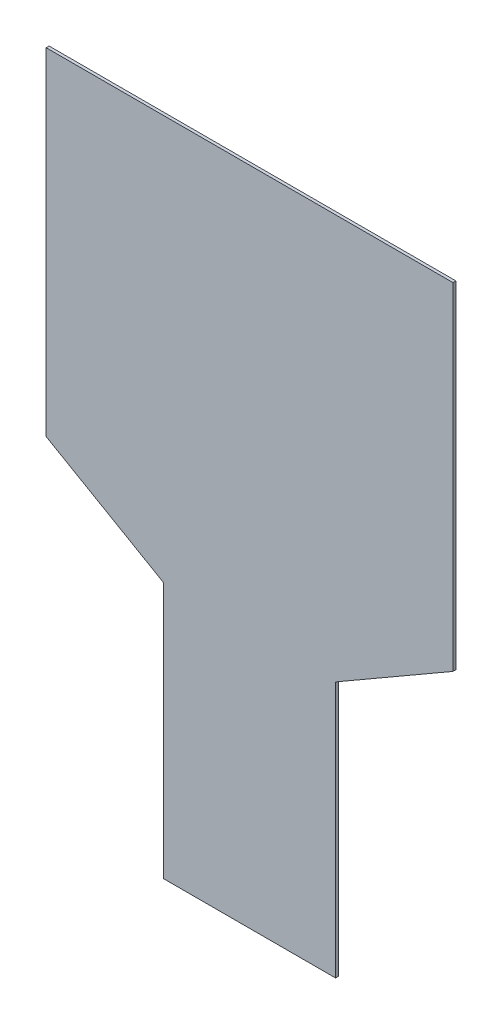
from build123d import *

# Parameters (mm, degrees)
RESSALTO_EXTRUS_O1_DEPTH = 1.5


with BuildPart() as part:
    # Esboço1 → Ressalto-extrusão1 (new body)
    with BuildSketch(Plane.XY):
        Polygon((106.237655735, 175.652651921), (-101.762344265, 175.652651921), (-101.762344265, 3.418023725), (-41.762344265, -31.222992426), (-41.762344265, -162.347348079), (46.237655735, -162.347348079), (46.237655735, -31.222992426), (106.237655735, 3.418023725), align=None)
    extrude(amount=RESSALTO_EXTRUS_O1_DEPTH)


solid = part.part
